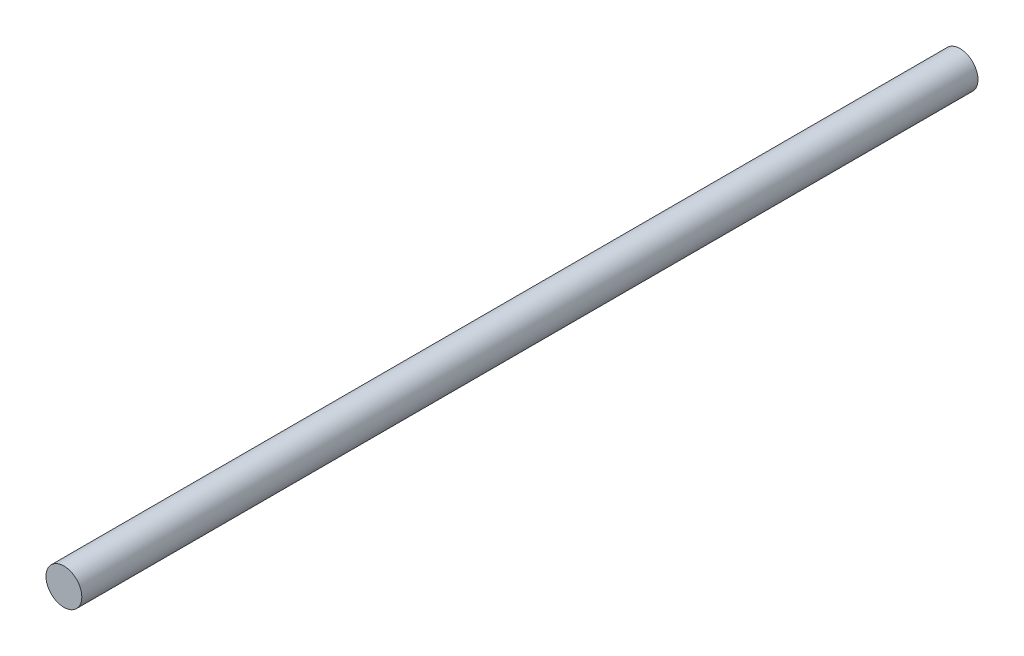
from build123d import *

# Parameters (mm, degrees)
CROQUIS1_R              = 4
SALIENTE_EXTRUIR1_DEPTH = 200


with BuildPart() as part:
    # Croquis1 → Saliente-Extruir1 (new body)
    with BuildSketch(Plane.XY):
        Circle(CROQUIS1_R)
    extrude(amount=SALIENTE_EXTRUIR1_DEPTH)


solid = part.part
